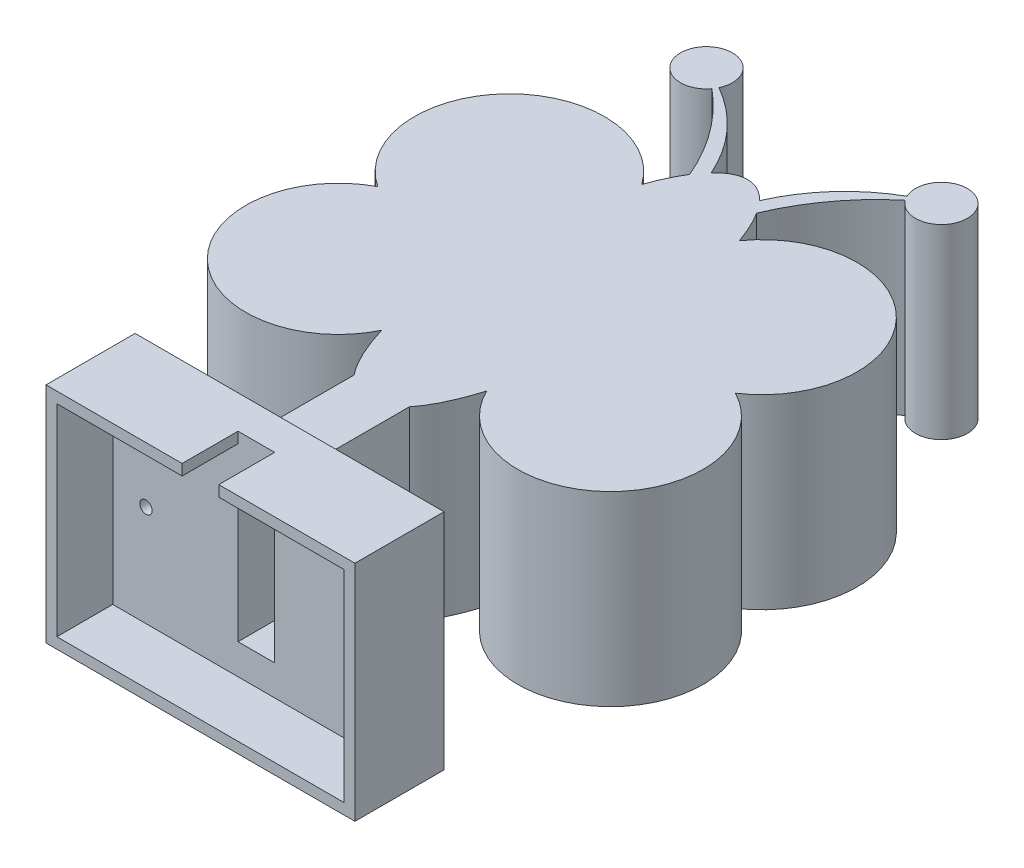
from build123d import *

# Parameters (mm, degrees)
BOSS_EXTRUDE1_DEPTH   = 60
BOSS_EXTRUDE1_2_DEPTH = 60
BOSS_EXTRUDE2_DEPTH   = 60
SKETCH5_W             = 11.80892804
SKETCH5_H             = 46.036446736
CUT_EXTRUDE1_DEPTH    = 96
SKETCH6_W             = 121.736344994
SKETCH6_H             = 10.703718027
BOSS_EXTRUDE5_DEPTH   = 6
SKETCH8_W             = 121.736344994
SKETCH8_H             = 10.703718027
BOSS_EXTRUDE6_DEPTH   = 6
SKETCH9_W             = 10.703718027
SKETCH9_H             = 72
CUT_EXTRUDE2_DEPTH    = 11.12
SKETCH10_W            = 10.703718027
SKETCH10_H            = 72
CUT_EXTRUDE3_DEPTH    = 11.12
SKETCH11_W            = 99.496344994
SKETCH11_H            = 72
SKETCH11_W_2          = 92.496344994
SKETCH11_H_2          = 65
BOSS_EXTRUDE7_DEPTH   = 18
SKETCH13_W            = 11.80892804
SKETCH13_H            = 18
CUT_EXTRUDE4_DEPTH    = 18
CUT_EXTRUDE5_REACH    = 217.226


with BuildPart() as part:
    # Sketch2 → Boss-Extrude1 (new body)
    with BuildSketch(Plane(origin=(0, 0, 0), x_dir=(1, 0, 0), z_dir=(0, 1, 0))):
        with BuildLine():
            add(Edge.make_bspline(
                [(7.777313634, 57.580294912), (4.018004463, 61.542658867), (0, 61.542658867)],
                knots=[5.922388911, 5.922388911, 5.922388911, 6.283185307, 6.283185307, 6.283185307], degree=2, weights=[1, 0.983772326, 1]))
            add(Edge.make_bspline(
                [(0, 61.542658867), (-4.018004463, 61.542658867), (-7.777313634, 57.580294912)],
                knots=[0, 0, 0, 0.360796396, 0.360796396, 0.360796396], degree=2, weights=[1, 0.983772326, 1]))
            ThreePointArc((-7.777313634, 57.580294912), (-17.007519977, 71.883457215), (-30.273865697, 82.550285809))
            ThreePointArc((-30.273865697, 82.550285809), (-45.006964161, 90.370546247), (-31.116710716, 81.135746686))
            ThreePointArc((-31.116710716, 81.135746686), (-19.299209246, 68.615142689), (-10.798016849, 53.643549812))
            add(Edge.make_bspline(
                [(-10.798016849, 53.643549812), (-13.519932633, 49.368001998), (-15.70928604, 43.147803925)],
                knots=[0.512241162, 0.512241162, 0.512241162, 0.793851756, 0.793851756, 0.793851756], degree=2, weights=[1, 0.990103302, 1]))
            ThreePointArc((-15.70928604, 43.147803925), (-62.630509673, 46.791979985), (-57.591476489, 0))
            ThreePointArc((-57.591476489, 0), (-64.587633529, -47.909506078), (-16.922901007, -39.404198342))
            add(Edge.make_bspline(
                [(-16.922901007, -39.404198342), (-13.612763141, -50.497708668), (-8.881626587, -56.319902877)],
                knots=[2.265651961, 2.265651961, 2.265651961, 2.726641474, 2.726641474, 2.726641474], degree=2, weights=[1, 0.973553482, 1]))
            Line((-8.881626587, -56.319902877), (8.881626587, -56.319902877))
            add(Edge.make_bspline(
                [(8.881626587, -56.319902877), (13.612763141, -50.497708668), (16.922901007, -39.404198342)],
                knots=[3.556543833, 3.556543833, 3.556543833, 4.017533346, 4.017533346, 4.017533346], degree=2, weights=[1, 0.973553482, 1]))
            ThreePointArc((16.922901007, -39.404198342), (64.587633529, -47.909506078), (57.591476489, 0))
            ThreePointArc((57.591476489, 0), (62.630509673, 46.791979985), (15.70928604, 43.147803925))
            add(Edge.make_bspline(
                [(15.70928604, 43.147803925), (13.519932633, 49.368001998), (10.798016849, 53.643549812)],
                knots=[5.489333551, 5.489333551, 5.489333551, 5.770944145, 5.770944145, 5.770944145], degree=2, weights=[1, 0.990103302, 1]))
            ThreePointArc((10.798016849, 53.643549812), (19.299209246, 68.615142689), (31.116710716, 81.135746686))
            ThreePointArc((31.116710716, 81.135746686), (45.006964161, 90.370546247), (30.273865697, 82.550285809))
            ThreePointArc((30.273865697, 82.550285809), (17.007519977, 71.883457215), (7.777313634, 57.580294912))
        make_face()
    extrude(amount=BOSS_EXTRUDE1_DEPTH)



with BuildPart() as body_2:
    # Sketch2 → Boss-Extrude1 2 (new body)
    with BuildSketch(Plane(origin=(0, 0, 0), x_dir=(1, 0, 0), z_dir=(0, 1, 0))):
        with BuildLine():
            add(Edge.make_bspline(
                [(0, -61.542658867), (4.637595748, -61.542658867), (8.881626587, -56.319902877)],
                knots=[3.141592654, 3.141592654, 3.141592654, 3.556543833, 3.556543833, 3.556543833], degree=2, weights=[1, 0.978554036, 1]))
            add(Edge.make_bspline(
                [(-8.881626587, -56.319902877), (-4.637595748, -61.542658867), (0, -61.542658867)],
                knots=[2.726641474, 2.726641474, 2.726641474, 3.141592654, 3.141592654, 3.141592654], degree=2, weights=[1, 0.978554036, 1]))
            Line((-8.881626587, -56.319902877), (-8.881626587, -86.003647397))
            Line((-8.881626587, -86.003647397), (-60.868172497, -86.003647397))
            Line((-60.868172497, -86.003647397), (-60.868172497, -96.707365424))
            Line((-60.868172497, -96.707365424), (60.868172497, -96.707365424))
            Line((60.868172497, -96.707365424), (60.868172497, -86.003647397))
            Line((60.868172497, -86.003647397), (8.881626587, -86.003647397))
            Line((8.881626587, -86.003647397), (8.881626587, -56.319902877))
        make_face()
    extrude(amount=BOSS_EXTRUDE1_2_DEPTH)


with BuildPart() as part_1:
    add(part.part)

    add(body_2.part)  # Boss-Extrude2 merges body 2
    # Sketch2_4 → Boss-Extrude2 (add)
    with BuildSketch(Plane(origin=(0, 0, 0), x_dir=(1, 0, 0), z_dir=(0, 1, 0))):
        with BuildLine():
            Line((8.881626587, -56.319902877), (-8.881626587, -56.319902877))
            add(Edge.make_bspline(
                [(-8.881626587, -56.319902877), (-4.637595748, -61.542658867), (0, -61.542658867)],
                knots=[2.726641474, 2.726641474, 2.726641474, 3.141592654, 3.141592654, 3.141592654], degree=2, weights=[1, 0.978554036, 1]))
            add(Edge.make_bspline(
                [(0, -61.542658867), (4.637595748, -61.542658867), (8.881626587, -56.319902877)],
                knots=[3.141592654, 3.141592654, 3.141592654, 3.556543833, 3.556543833, 3.556543833], degree=2, weights=[1, 0.978554036, 1]))
        make_face()
    extrude(amount=BOSS_EXTRUDE2_DEPTH)

    # Sketch5 → Cut-Extrude1 (cut)
    with BuildSketch(Plane.XY.offset(96.707365424)):
        with Locations((0, 30.304042831)):
            Rectangle(SKETCH5_W, SKETCH5_H)
    extrude(amount=-CUT_EXTRUDE1_DEPTH, mode=Mode.SUBTRACT)

    # Sketch6 → Boss-Extrude5 (add)
    with BuildSketch(Plane(origin=(0, 60, 0), x_dir=(1, 0, 0), z_dir=(0, 1, 0))):
        with Locations((0, -91.35550641)):
            Rectangle(SKETCH6_W, SKETCH6_H)
    extrude(amount=BOSS_EXTRUDE5_DEPTH)

    # Sketch8 → Boss-Extrude6 (add)
    with BuildSketch(Plane.XZ):
        with Locations((0, 91.35550641)):
            Rectangle(SKETCH8_W, SKETCH8_H)
    extrude(amount=BOSS_EXTRUDE6_DEPTH)

    # Sketch9 → Cut-Extrude2 (cut)
    with BuildSketch(Plane(origin=(60.868172497, 0, 0), x_dir=(0, 0, -1), z_dir=(1, 0, 0))):
        with Locations((-91.35550641, 30)):
            Rectangle(SKETCH9_W, SKETCH9_H)
    extrude(amount=-CUT_EXTRUDE2_DEPTH, mode=Mode.SUBTRACT)

    # Sketch10 → Cut-Extrude3 (cut)
    with BuildSketch(Plane.ZY.offset(60.868172497)):
        with Locations((91.35550641, 30)):
            Rectangle(SKETCH10_W, SKETCH10_H)
    extrude(amount=-CUT_EXTRUDE3_DEPTH, mode=Mode.SUBTRACT)

    # Sketch11 → Boss-Extrude7 (add)
    with BuildSketch(Plane.XY.offset(96.707365424)):
        with Locations((0, 30)):
            Rectangle(SKETCH11_W, SKETCH11_H)
        with Locations((0, 30)):
            Rectangle(SKETCH11_W_2, SKETCH11_H_2, mode=Mode.SUBTRACT)
    extrude(amount=BOSS_EXTRUDE7_DEPTH)

    # Sketch13 → Cut-Extrude4 (cut)
    with BuildSketch(Plane.XZ.offset(-62.5)):
        with Locations((0, 105.707365424)):
            Rectangle(SKETCH13_W, SKETCH13_H)
    extrude(amount=-CUT_EXTRUDE4_DEPTH, mode=Mode.SUBTRACT)

    # Sketch14 → Cut-Extrude5 (cut, up to next)
    with BuildSketch(Plane.XY.offset(96.707365424), mode=Mode.PRIVATE) as cut_extrude5_sk1:
        with BuildLine():
            ThreePointArc((-37.548172497, 30), (-35.548172497, 28), (-33.548172497, 30))
            ThreePointArc((-33.548172497, 30), (-35.548172497, 32), (-37.548172497, 30))
        make_face()
    cut_extrude5_tool1 = extrude(cut_extrude5_sk1.sketch, amount=-CUT_EXTRUDE5_REACH, mode=Mode.PRIVATE) & part_1.part
    add(cut_extrude5_tool1.solids().sort_by_distance((-35.548172, 30, 96.707365))[0], mode=Mode.SUBTRACT)


solid = part_1.part
